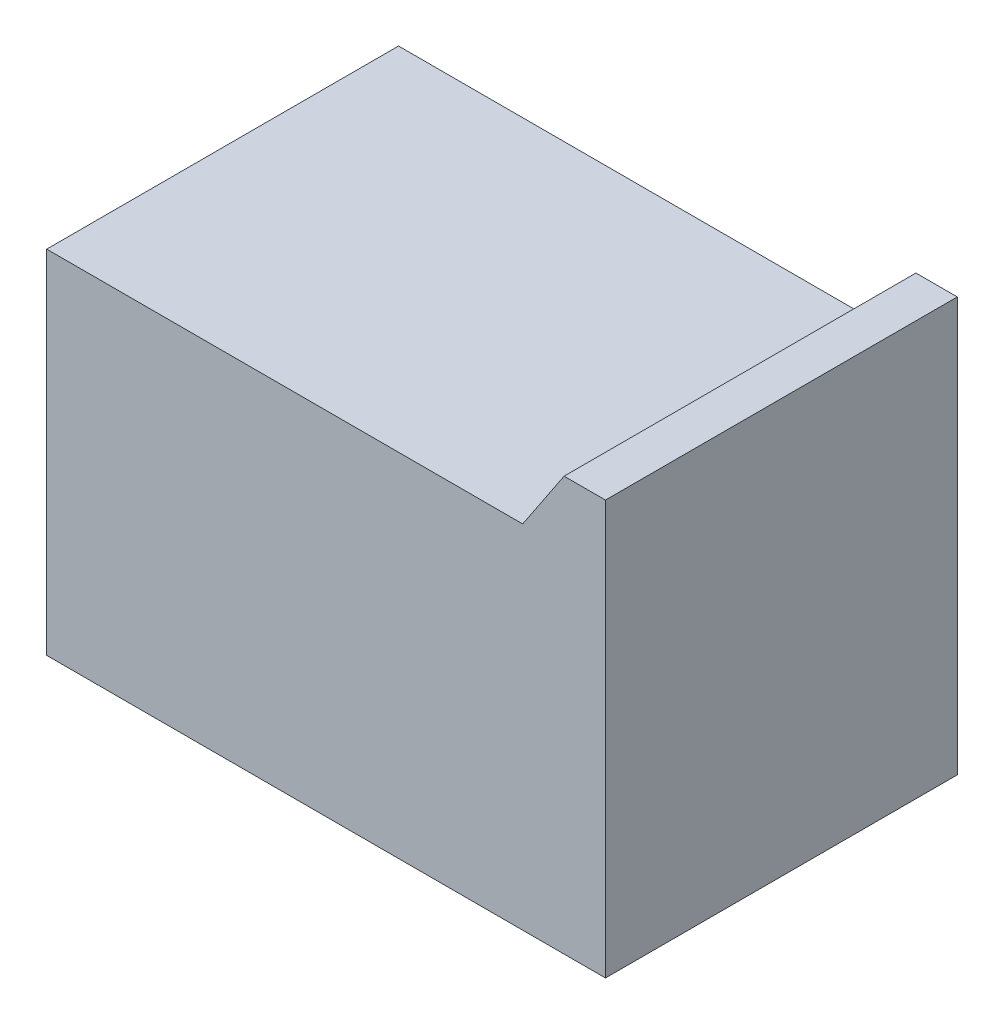
from build123d import *

# Parameters (mm, degrees)
SKETCH1_W           = 685.8
SKETCH1_H           = 431.8
BOSS_EXTRUDE1_DEPTH = 508
CUT_EXTRUDE1_DEPTH  = 432.8


with BuildPart() as part:
    # Sketch1 → Boss-Extrude1 (new body)
    with BuildSketch(Plane(origin=(0, 0, 0), x_dir=(1, 0, 0), z_dir=(0, 1, 0))):
        Rectangle(SKETCH1_W, SKETCH1_H)
    extrude(amount=BOSS_EXTRUDE1_DEPTH)

    # Sketch2 → Cut-Extrude1 (cut, through all)
    with BuildSketch(Plane.XY.offset(215.9)):
        Polygon((-342.9, 431.8), (241.3, 431.8), (292.1, 508), (-342.9, 508), align=None)
    extrude(amount=-CUT_EXTRUDE1_DEPTH, mode=Mode.SUBTRACT)


solid = part.part
